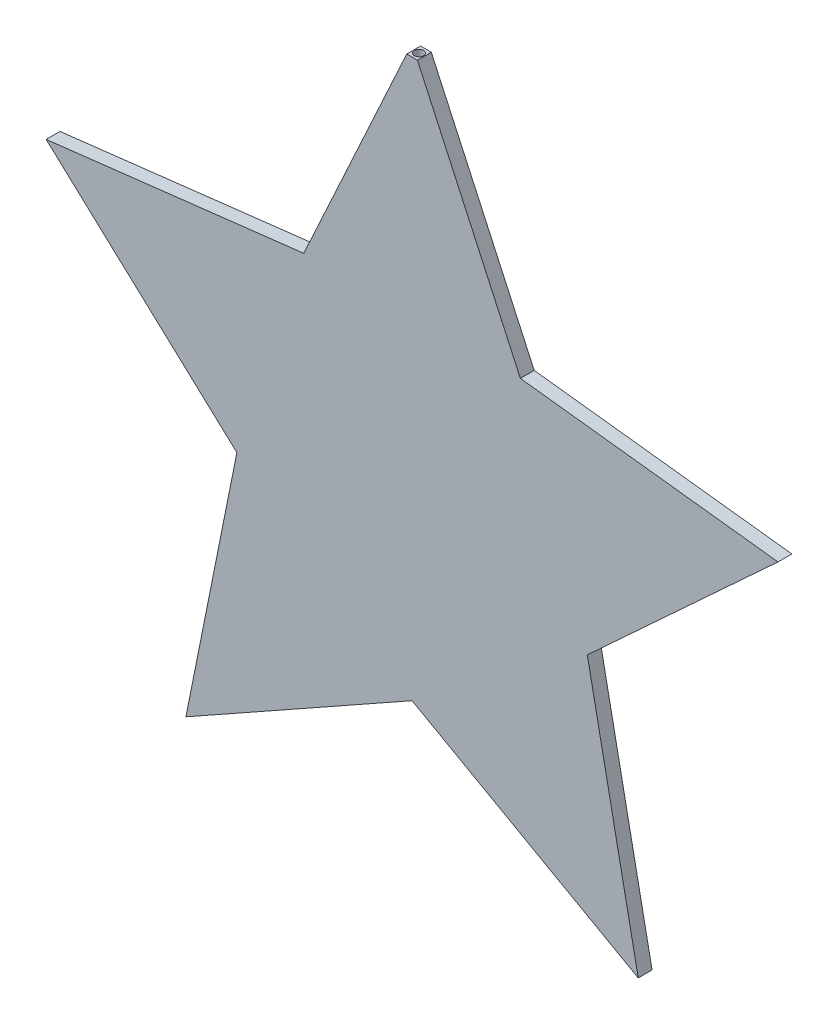
from build123d import *

# Parameters (mm, degrees)
BOSS_EXTRUDE1_DEPTH = 1.5
SKETCH3_R           = 1
CUT_EXTRUDE1_DEPTH  = 217
CUT_EXTRUDE2_DEPTH  = 5


with BuildPart() as part:
    # Sketch1 → Boss-Extrude1 (new body, symmetric)
    with BuildSketch(Plane.XY):
        Polygon((-49.04162064, 0), (0, 27.549626948), (49.04162064, 0), (37.99506262, 55.154655795), (79.351009059, 93.282705759), (23.482240104, 99.820530731), (0, 150.934588481), (-23.482240104, 99.820530731), (-79.351009059, 93.282705759), (-37.99506262, 55.154655795), align=None)
    extrude(amount=BOSS_EXTRUDE1_DEPTH, both=True)

    # Sketch3 → Cut-Extrude1 (cut)
    with BuildSketch(Plane(origin=(0, 0, 0), x_dir=(1, 0, 0), z_dir=(0, 1, 0))):
        with Locations(Location((0, 0, 0), (0, 0, 90))):  # turned: the seam where the file's is
            Circle(SKETCH3_R)
    extrude(amount=CUT_EXTRUDE1_DEPTH, mode=Mode.SUBTRACT)

    # Sketch4 → Cut-Extrude2 (cut, symmetric)
    with BuildSketch(Plane.XY):
        Polygon((-1.634845192, 148.415891617), (1.929257944, 148.415891617), (0, 151.970633461), align=None)
    extrude(amount=CUT_EXTRUDE2_DEPTH, both=True, mode=Mode.SUBTRACT)


solid = part.part
